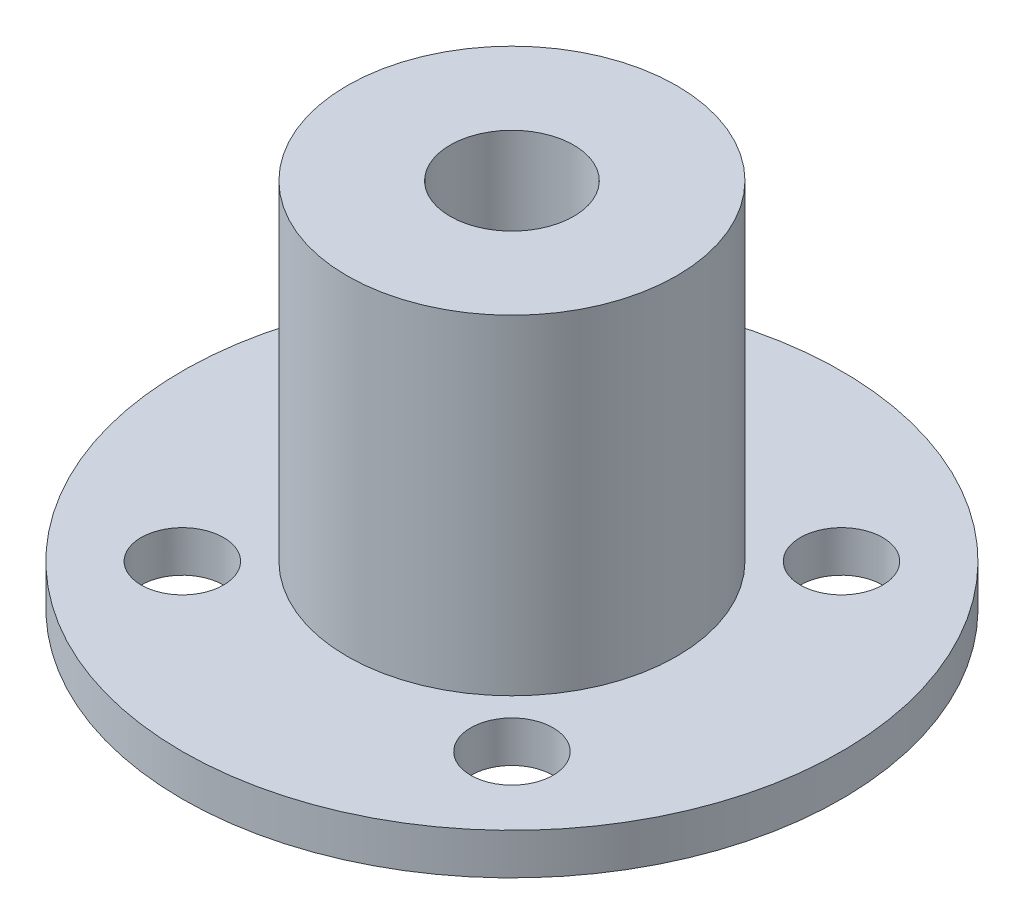
from build123d import *

# Parameters (mm, degrees)
SKETCH1_R           = 25.4
BOSS_EXTRUDE1_DEPTH = 3.175
SKETCH2_R           = 12.7
SKETCH2_R_2         = 4.7625
BOSS_EXTRUDE2_DEPTH = 25.4
SKETCH3_R           = 3.175
CUT_EXTRUDE1_DEPTH  = 29.575


with BuildPart() as part:
    # Sketch1 → Boss-Extrude1 (new body)
    with BuildSketch(Plane(origin=(0, 0, 0), x_dir=(1, 0, 0), z_dir=(0, 1, 0))):
        Circle(SKETCH1_R)
    extrude(amount=BOSS_EXTRUDE1_DEPTH)

    # Sketch2 → Boss-Extrude2 (add)
    with BuildSketch(Plane(origin=(0, 3.175, 0), x_dir=(1, 0, 0), z_dir=(0, 1, 0))):
        Circle(SKETCH2_R)
        Circle(SKETCH2_R_2, mode=Mode.SUBTRACT)
    extrude(amount=BOSS_EXTRUDE2_DEPTH)

    # Sketch3 → Cut-Extrude1 (cut, through all)
    with BuildSketch(Plane.XZ):
        with Locations((-12.7, 12.7)):
            Circle(SKETCH3_R)
        with Locations((12.7, 12.7)):
            Circle(SKETCH3_R)
        with Locations((12.7, -12.7)):
            Circle(SKETCH3_R)
        with Locations((-12.7, -12.7)):
            Circle(SKETCH3_R)
    extrude(amount=-CUT_EXTRUDE1_DEPTH, mode=Mode.SUBTRACT)


solid = part.part
